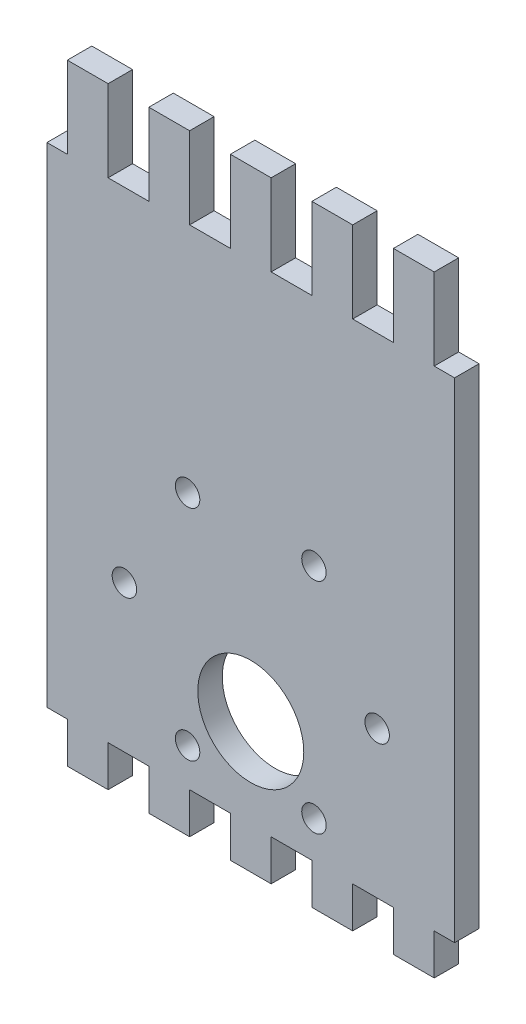
from build123d import *

# Parameters (mm, degrees)
ESQUISSE3_W                = 50
ESQUISSE3_H                = 60
BOSS_EXTRU_12_DEPTH        = 3
ESQUISSE4_R                = 1.5
ENL_V_MAT_EXTRU_1_DEPTH    = 5
ESQUISSE6_R                = 6.5
ENL_V_MAT_EXTRU_3_DEPTH    = 10
ESQUISSE7_W                = 5
ESQUISSE7_H                = 10
ESQUISSE7_H_2              = 5
BOSS_EXTRU_13_DEPTH        = 3
R_P_TITION_LIN_AIRE1_COUNT = 5
R_P_TITION_LIN_AIRE1_PITCH = 10


with BuildPart() as part:
    # Esquisse3 → Boss.-Extru.12 (new body)
    with BuildSketch(Plane.XY):
        with Locations((0, -8)):
            Rectangle(ESQUISSE3_W, ESQUISSE3_H)
    extrude(amount=BOSS_EXTRU_12_DEPTH)

    # Esquisse4 → Enlèv. mat.-Extru.1 (cut)
    with BuildSketch(Plane.XY.offset(3)):
        with Locations((-7.75, -6.576606241)):
            Circle(ESQUISSE4_R)
        with Locations((-15.5, -20)):
            Circle(ESQUISSE4_R)
        with Locations((-7.75, -33.423393759)):
            Circle(ESQUISSE4_R)
    enl_v_mat_extru_1 = extrude(amount=-ENL_V_MAT_EXTRU_1_DEPTH, mode=Mode.SUBTRACT)

    # Esquisse6 → Enlèv. mat.-Extru.3 (cut)
    with BuildSketch(Plane.XY.offset(3)):
        with Locations((0, -27)):
            Circle(ESQUISSE6_R)
    extrude(amount=-ENL_V_MAT_EXTRU_3_DEPTH, mode=Mode.SUBTRACT)

    # Symétrie3: Enlèv. mat.-Extru.1 across plane
    add(enl_v_mat_extru_1.mirror(Plane(origin=(0, 0, 0), x_dir=(0, 0, 1), z_dir=(1, 0, 0))), mode=Mode.SUBTRACT)

    # Esquisse7 → Boss.-Extru.13 (add)
    with BuildSketch(Plane.XY.offset(3)):
        with Locations((-20, 27)):
            Rectangle(ESQUISSE7_W, ESQUISSE7_H)
        with Locations((-20, -40.5)):
            Rectangle(ESQUISSE7_W, ESQUISSE7_H_2)
    boss_extru_13 = extrude(amount=-BOSS_EXTRU_13_DEPTH)

    # Répétition linéaire1: Boss.-Extru.13 ×5
    with Locations(*[(i * R_P_TITION_LIN_AIRE1_PITCH, 0, 0) for i in range(1, R_P_TITION_LIN_AIRE1_COUNT)]):
        add(boss_extru_13)


solid = part.part
